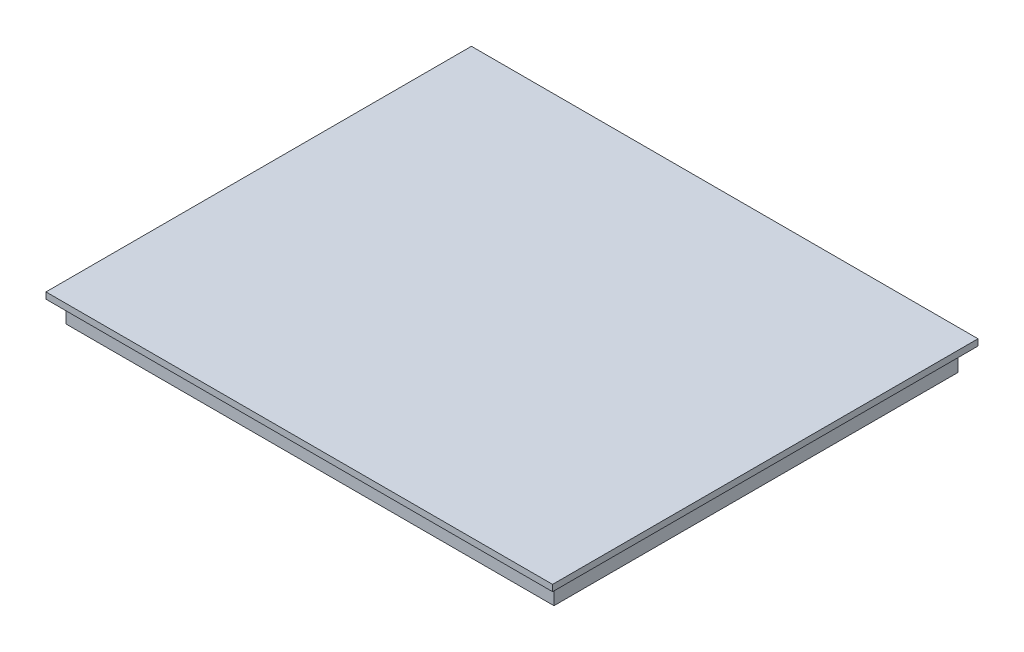
from build123d import *

# Parameters (mm, degrees)
SKETCH_1_W      = 76.7
SKETCH_1_H      = 63.5
EXTRUDE_1_DEPTH = 3.5
SKETCH_2_W      = 79.66
SKETCH_2_H      = 66.9
EXTRUDE_2_DEPTH = 1


with BuildPart() as part:
    # 草图1 → 凸台-拉伸1 (new body)
    with BuildSketch(Plane(origin=(0, 0, 0), x_dir=(1, 0, 0), z_dir=(0, 1, 0))):
        Rectangle(SKETCH_1_W, SKETCH_1_H)
    extrude(amount=EXTRUDE_1_DEPTH)

    # 草图2 → 凸台-拉伸2 (add)
    with BuildSketch(Plane(origin=(0, 3.5, 0), x_dir=(1, 0, 0), z_dir=(0, 1, 0))):
        Rectangle(SKETCH_2_W, SKETCH_2_H)
    extrude(amount=EXTRUDE_2_DEPTH)


solid = part.part
